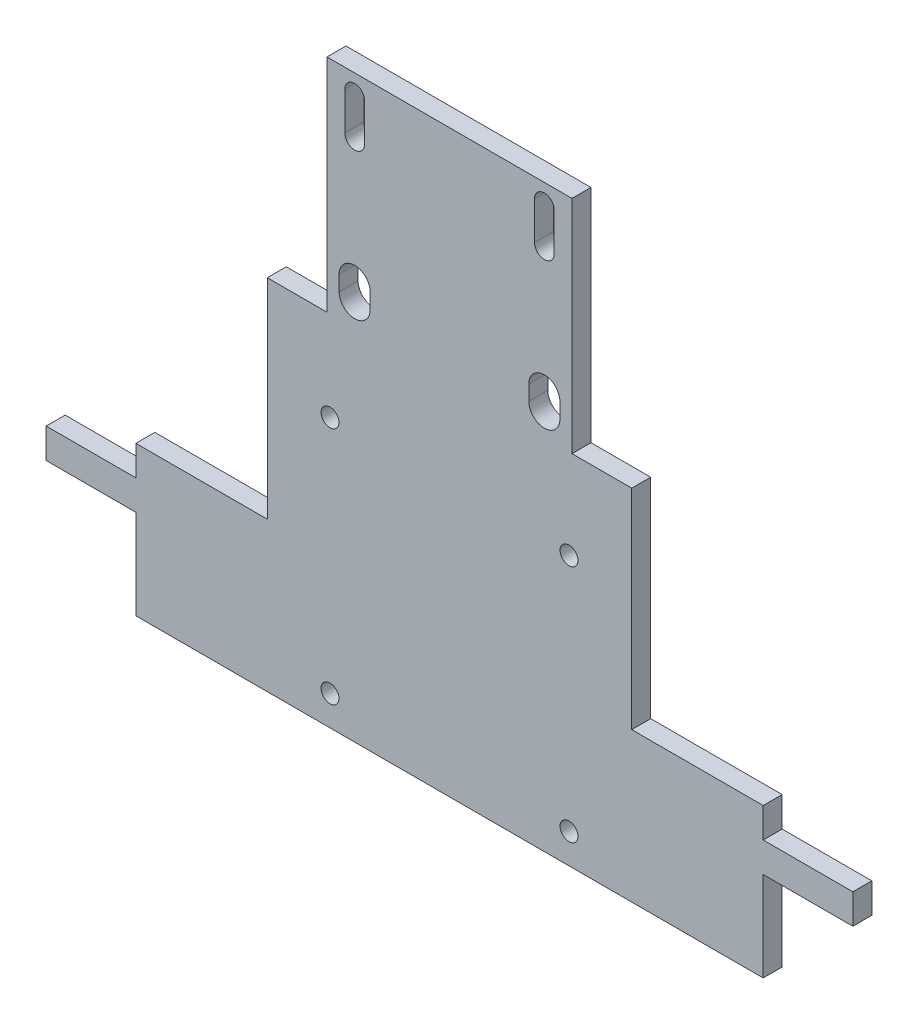
from build123d import *

# Parameters (mm, degrees)
SKETCH1_R           = 0.15
BOSS_EXTRUDE1_DEPTH = 0.3175
SCALE1_SCALE        = 10


with BuildPart() as part:
    # Sketch1 → Boss-Extrude1 (new body)
    with BuildSketch(Plane.XY):
        Polygon((0, 0), (10.5, 0), (10.5, 1.5), (12, 1.5), (12, 2), (10.5, 2), (10.5, 2.5), (8.3, 2.5), (8.3, 6), (7.3, 6), (7.3, 9.7), (3.2, 9.7), (3.2, 6), (2.2, 6), (2.2, 2.5), (0, 2.5), (0, 2), (-1.5, 2), (-1.5, 1.5), (0, 1.5), align=None)
        with Locations((3.25, 0.5)):
            Circle(SKETCH1_R, mode=Mode.SUBTRACT)
        with Locations((7.25, 0.5)):
            Circle(SKETCH1_R, mode=Mode.SUBTRACT)
        with Locations((7.25, 4.5)):
            Circle(SKETCH1_R, mode=Mode.SUBTRACT)
        with Locations((3.25, 4.5)):
            Circle(SKETCH1_R, mode=Mode.SUBTRACT)
        with BuildLine():
            Line((3.8275, 9.382), (3.8275, 8.747))
            ThreePointArc((3.8275, 8.747), (3.6625, 8.582), (3.4975, 8.747))
            Line((3.4975, 8.747), (3.4975, 9.382))
            ThreePointArc((3.4975, 9.382), (3.6625, 9.547), (3.8275, 9.382))
        make_face(mode=Mode.SUBTRACT)
        with BuildLine():
            Line((6.6725, 9.382), (6.6725, 8.747))
            ThreePointArc((6.6725, 8.747), (6.8375, 8.582), (7.0025, 8.747))
            Line((7.0025, 8.747), (7.0025, 9.382))
            ThreePointArc((7.0025, 9.382), (6.8375, 9.547), (6.6725, 9.382))
        make_face(mode=Mode.SUBTRACT)
        with BuildLine():
            Line((3.4025, 6.3975), (3.4025, 6.6515))
            ThreePointArc((3.4025, 6.6515), (3.6625, 6.9115), (3.9225, 6.6515))
            Line((3.9225, 6.6515), (3.9225, 6.3975))
            ThreePointArc((3.9225, 6.3975), (3.6625, 6.1375), (3.4025, 6.3975))
        make_face(mode=Mode.SUBTRACT)
        with BuildLine():
            Line((7.0975, 6.3975), (7.0975, 6.6515))
            ThreePointArc((7.0975, 6.6515), (6.8375, 6.9115), (6.5775, 6.6515))
            Line((6.5775, 6.6515), (6.5775, 6.3975))
            ThreePointArc((6.5775, 6.3975), (6.8375, 6.1375), (7.0975, 6.3975))
        make_face(mode=Mode.SUBTRACT)
    extrude(amount=BOSS_EXTRUDE1_DEPTH)


with BuildPart() as part_1:
    # Scale1: scaled about (5.25, 3.742866372, 0.15875)
    add(part.part.scale(SCALE1_SCALE).moved(Location((-47.25, -33.685797348, -1.42875))))


solid = part_1.part
